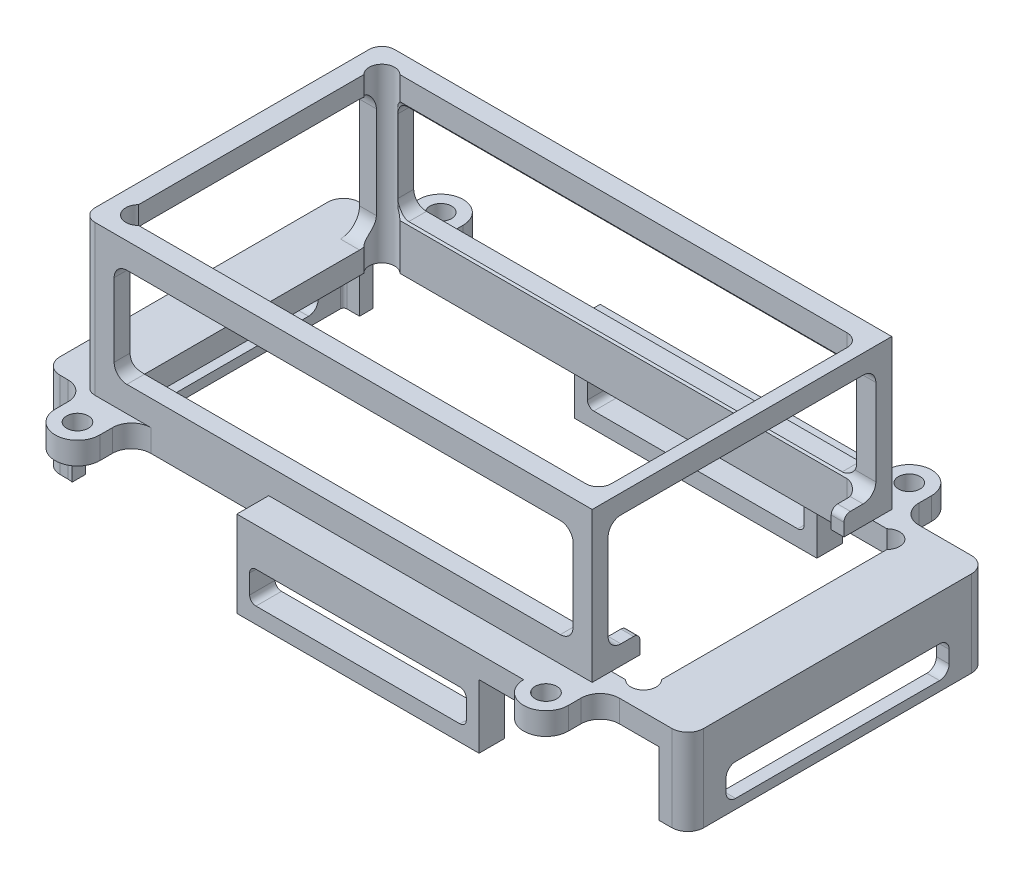
from build123d import *

# Parameters (mm, degrees)
EXTRUDE_1_DEPTH     = 23.5
SKETCH_2_R          = 1.7
EXTRUDE_2_DEPTH     = 3.5
FILLET_1_R          = 2.5
EXTRUDE_1_2_DEPTH   = 10
CUT_EXTRUDE_1_REACH = 97
CUT_EXTRUDE_2_DEPTH = 47
CUT_EXTRUDE_3_REACH = 88
CUT_EXTRUDE_4_DEPTH = 3.5
CUT_EXTRUDE_5_REACH = 4
SKETCH_9_W          = 45
SKETCH_9_H          = 3.5
EXTRUDE_3_DEPTH     = 5
SKETCH_10_W         = 45
SKETCH_10_H         = 3.5
EXTRUDE_4_DEPTH     = 5
SKETCH_11_W         = 38
SKETCH_11_H         = 4
EXTRUDE_5_DEPTH     = 10
CUT_EXTRUDE_6_DEPTH = 57
FILLET_3_R          = 3


with BuildPart() as part:
    # 草图1 → Extrude 1 (new body)
    with BuildSketch(Plane(origin=(0, 0, 0), x_dir=(1, 0, 0), z_dir=(0, 1, 0))):
        with BuildLine():
            Line((-38, 23.5), (40, 23.5))
            Line((40, 23.5), (40, -23.5))
            Line((40, -23.5), (-38, -23.5))
            ThreePointArc((-38, -23.5), (-39.414213562, -22.914213562), (-40, -21.5))
            Line((-40, -21.5), (-40, 21.5))
            ThreePointArc((-40, 21.5), (-39.414213562, 22.914213562), (-38, 23.5))
        make_face()
        with BuildLine():
            Line((-34.171572875, -20.5), (36, -20.5))
            ThreePointArc((36, -20.5), (37.414213562, -19.914213562), (38, -18.5))
            Line((38, -18.5), (38, 18.5))
            ThreePointArc((38, 18.5), (37.414213562, 19.914213562), (36, 20.5))
            Line((36, 20.5), (-34.171572875, 20.5))
            ThreePointArc((-34.171572875, 20.5), (-37, 20.5), (-37, 17.671572875))
            Line((-37, 17.671572875), (-37, -17.671572875))
            ThreePointArc((-37, -17.671572875), (-37, -20.5), (-34.171572875, -20.5))
        make_face(mode=Mode.SUBTRACT)
    extrude(amount=EXTRUDE_1_DEPTH)

    # 草图2 → 凸台-拉伸2 (add)
    with BuildSketch(Plane.XZ):
        with BuildLine():
            Line((55, 0), (55, 23.5))
            Line((55, 23.5), (41.25, 23.5))
            Line((41.25, 23.5), (41.25, 28.5))
            ThreePointArc((41.25, 28.5), (37.75, 32), (34.25, 28.5))
            Line((34.25, 28.5), (34.25, 23.5))
            Line((34.25, 23.5), (-32.25, 23.5))
            Line((-32.25, 23.5), (-32.25, 28.5))
            ThreePointArc((-32.25, 28.5), (-35.75, 32), (-39.25, 28.5))
            Line((-39.25, 28.5), (-39.25, 23.5))
            Line((-39.25, 23.5), (-46, 23.5))
            Line((-46, 23.5), (-46, -23.5))
            Line((-46, -23.5), (-39.25, -23.5))
            Line((-39.25, -23.5), (-39.25, -28.5))
            ThreePointArc((-39.25, -28.5), (-35.75, -32), (-32.25, -28.5))
            Line((-32.25, -28.5), (-32.25, -23.5))
            Line((-32.25, -23.5), (34.25, -23.5))
            Line((34.25, -23.5), (34.25, -28.5))
            ThreePointArc((34.25, -28.5), (37.75, -32), (41.25, -28.5))
            Line((41.25, -28.5), (41.25, -23.5))
            Line((41.25, -23.5), (55, -23.5))
            Line((55, -23.5), (55, 0))
        make_face()
        with Locations((37.75, 28.5)):
            Circle(SKETCH_2_R, mode=Mode.SUBTRACT)
        with Locations((37.75, -28.5)):
            Circle(SKETCH_2_R, mode=Mode.SUBTRACT)
        with Locations((-35.75, -28.5)):
            Circle(SKETCH_2_R, mode=Mode.SUBTRACT)
        with Locations((-35.75, 28.5)):
            Circle(SKETCH_2_R, mode=Mode.SUBTRACT)
        with BuildLine():
            Line((-34.171572875, 20.5), (42.231907087, 20.5))
            ThreePointArc((42.231907087, 20.5), (45.060334211, 20.5), (45.060334211, 17.671572875))
            Line((45.060334211, 17.671572875), (45.060334211, -17.671572875))
            ThreePointArc((45.060334211, -17.671572875), (45.060334211, -20.5), (42.231907087, -20.5))
            Line((42.231907087, -20.5), (-34.171572875, -20.5))
            ThreePointArc((-34.171572875, -20.5), (-37, -20.5), (-37, -17.671572875))
            Line((-37, -17.671572875), (-37, 17.671572875))
            ThreePointArc((-37, 17.671572875), (-37, 20.5), (-34.171572875, 20.5))
        make_face(mode=Mode.SUBTRACT)
    extrude(amount=EXTRUDE_2_DEPTH)

    # 圆角1
    fillet_1_edges = [part.edges().sort_by_distance(p)[0] for p in [
        (55, -1.75, -23.5),
        (55, -1.75, 23.5),
        (-46, -1.75, 23.5),
        (-46, -1.75, -23.5),
    ]]
    fillet(fillet_1_edges, radius=FILLET_1_R)

    # 草图3 → Extrude 1 2 (add)
    with BuildSketch(Plane.XZ.offset(3.5)):
        with BuildLine():
            Line((50.5, -23.5), (52.5, -23.5))
            ThreePointArc((52.5, -23.5), (54.267766953, -22.767766953), (55, -21))
            Line((55, -21), (55, 21))
            ThreePointArc((55, 21), (54.267766953, 22.767766953), (52.5, 23.5))
            Line((52.5, 23.5), (50.5, 23.5))
            Line((50.5, 23.5), (50.5, 21.5))
            Line((50.5, 21.5), (52.5, 21.5))
            ThreePointArc((52.5, 21.5), (52.853553391, 21.353553391), (53, 21))
            Line((53, 21), (53, -21))
            ThreePointArc((53, -21), (52.853553391, -21.353553391), (52.5, -21.5))
            Line((52.5, -21.5), (50.5, -21.5))
            Line((50.5, -21.5), (50.5, -23.5))
        make_face()
        with BuildLine():
            Line((-41.5, 23.5), (-43.5, 23.5))
            ThreePointArc((-43.5, 23.5), (-45.267766953, 22.767766953), (-46, 21))
            Line((-46, 21), (-46, -21))
            ThreePointArc((-46, -21), (-45.267766953, -22.767766953), (-43.5, -23.5))
            Line((-43.5, -23.5), (-41.5, -23.5))
            Line((-41.5, -23.5), (-41.5, -21.5))
            Line((-41.5, -21.5), (-43.5, -21.5))
            ThreePointArc((-43.5, -21.5), (-43.853553391, -21.353553391), (-44, -21))
            Line((-44, -21), (-44, 21))
            ThreePointArc((-44, 21), (-43.853553391, 21.353553391), (-43.5, 21.5))
            Line((-43.5, 21.5), (-41.5, 21.5))
            Line((-41.5, 21.5), (-41.5, 23.5))
        make_face()
    extrude(amount=EXTRUDE_1_2_DEPTH)

    # 草图4 → 切除-拉伸1 (cut, up to next)
    with BuildSketch(Plane.ZY.offset(40), mode=Mode.PRIVATE) as cut_extrude_1_sk1:
        with BuildLine():
            Line((17, 0), (-17, 0))
            ThreePointArc((-17, 0), (-19.121320344, 0.878679656), (-20, 3))
            Line((-20, 3), (-20, 17.5))
            ThreePointArc((-20, 17.5), (-19.121320344, 19.621320344), (-17, 20.5))
            Line((-17, 20.5), (17, 20.5))
            ThreePointArc((17, 20.5), (19.121320344, 19.621320344), (20, 17.5))
            Line((20, 17.5), (20, 3))
            ThreePointArc((20, 3), (19.121320344, 0.878679656), (17, 0))
        make_face()
    cut_extrude_1_tool1 = extrude(cut_extrude_1_sk1.sketch, amount=-CUT_EXTRUDE_1_REACH, mode=Mode.PRIVATE) & part.part
    add(cut_extrude_1_tool1.solids().sort_by_distance((-40, 10.25, 0))[0], mode=Mode.SUBTRACT)

    # 草图5 → 切除-拉伸2 (cut)
    with BuildSketch(Plane(origin=(0, 0, -23.5), x_dir=(-1, 0, 0), z_dir=(0, 0, -1))):
        with BuildLine():
            Line((-37, 11.75), (-37, 17.5))
            ThreePointArc((-37, 17.5), (-36.414213562, 18.914213562), (-35, 19.5))
            Line((-35, 19.5), (33, 19.5))
            ThreePointArc((33, 19.5), (34.414213562, 18.914213562), (35, 17.5))
            Line((35, 17.5), (35, 6))
            ThreePointArc((35, 6), (34.414213562, 4.585786438), (33, 4))
            Line((33, 4), (-35, 4))
            ThreePointArc((-35, 4), (-36.414213562, 4.585786438), (-37, 6))
            Line((-37, 6), (-37, 11.75))
        make_face()
    extrude(amount=-CUT_EXTRUDE_2_DEPTH, mode=Mode.SUBTRACT)

    # 草图6 → 切除-拉伸3 (cut, up to next)
    with BuildSketch(Plane(origin=(40, 0, 0), x_dir=(0, 0, -1), z_dir=(1, 0, 0)), mode=Mode.PRIVATE) as cut_extrude_3_sk1:
        with BuildLine():
            Line((21, 5), (21, 18.5))
            ThreePointArc((21, 18.5), (20.414213562, 19.914213562), (19, 20.5))
            Line((19, 20.5), (-19, 20.5))
            ThreePointArc((-19, 20.5), (-20.414213562, 19.914213562), (-21, 18.5))
            Line((-21, 18.5), (-21, 5))
            ThreePointArc((-21, 5), (-20.414213562, 3.585786438), (-19, 3))
            Line((-19, 3), (-17, 3))
            ThreePointArc((-17, 3), (-16.292893219, 2.707106781), (-16, 2))
            Line((-16, 2), (-16, 0))
            Line((-16, 0), (16, 0))
            Line((16, 0), (16, 2))
            ThreePointArc((16, 2), (16.292893219, 2.707106781), (17, 3))
            Line((17, 3), (19, 3))
            ThreePointArc((19, 3), (20.414213562, 3.585786438), (21, 5))
        make_face()
    cut_extrude_3_tool1 = extrude(cut_extrude_3_sk1.sketch, amount=-CUT_EXTRUDE_3_REACH, mode=Mode.PRIVATE) & part.part
    add(cut_extrude_3_tool1.solids().sort_by_distance((40, 10.556936, 0))[0], mode=Mode.SUBTRACT)

    # 草图7 → 切除-拉伸4 (cut)
    with BuildSketch(Plane.ZY.offset(-53)):
        with BuildLine():
            Line((16, -12), (-16, -12))
            ThreePointArc((-16, -12), (-17.060660172, -11.560660172), (-17.5, -10.5))
            Line((-17.5, -10.5), (-17.5, -8.5))
            ThreePointArc((-17.5, -8.5), (-17.060660172, -7.439339828), (-16, -7))
            Line((-16, -7), (16, -7))
            ThreePointArc((16, -7), (17.060660172, -7.439339828), (17.5, -8.5))
            Line((17.5, -8.5), (17.5, -10.5))
            ThreePointArc((17.5, -10.5), (17.060660172, -11.560660172), (16, -12))
        make_face()
    extrude(amount=-CUT_EXTRUDE_4_DEPTH, mode=Mode.SUBTRACT)

    # 草图8 → 切除-拉伸5 (cut, up to next)
    with BuildSketch(Plane(origin=(-44, 0, 0), x_dir=(0, 0, -1), z_dir=(1, 0, 0)), mode=Mode.PRIVATE) as cut_extrude_5_sk1:
        with BuildLine():
            Line((16, -12), (-16, -12))
            ThreePointArc((-16, -12), (-17.060660172, -11.560660172), (-17.5, -10.5))
            Line((-17.5, -10.5), (-17.5, -8.5))
            ThreePointArc((-17.5, -8.5), (-17.060660172, -7.439339828), (-16, -7))
            Line((-16, -7), (16, -7))
            ThreePointArc((16, -7), (17.060660172, -7.439339828), (17.5, -8.5))
            Line((17.5, -8.5), (17.5, -10.5))
            ThreePointArc((17.5, -10.5), (17.060660172, -11.560660172), (16, -12))
        make_face()
    cut_extrude_5_tool1 = extrude(cut_extrude_5_sk1.sketch, amount=-CUT_EXTRUDE_5_REACH, mode=Mode.PRIVATE) & part.part
    add(cut_extrude_5_tool1.solids().sort_by_distance((-44, -9.5, 0))[0], mode=Mode.SUBTRACT)

    # 草图9 → 凸台-拉伸3 (add)
    with BuildSketch(Plane.XY.offset(23.5)):
        with Locations((11.75, -1.75)):
            Rectangle(SKETCH_9_W, SKETCH_9_H)
    extrude(amount=EXTRUDE_3_DEPTH)

    # 草图10 → 凸台-拉伸4 (add)
    with BuildSketch(Plane(origin=(0, 0, -23.5), x_dir=(-1, 0, 0), z_dir=(0, 0, -1))):
        with Locations((-11.75, -1.75)):
            Rectangle(SKETCH_10_W, SKETCH_10_H)
    extrude(amount=EXTRUDE_4_DEPTH)

    # 草图11 → 凸台-拉伸5 (add)
    with BuildSketch(Plane.XZ.offset(3.5)):
        with Locations((8.25, -26.5)):
            Rectangle(SKETCH_11_W, SKETCH_11_H)
        with Locations((8.25, 26.5)):
            Rectangle(SKETCH_11_W, SKETCH_11_H)
    extrude(amount=EXTRUDE_5_DEPTH)

    # 草图12 → 切除-拉伸6 (cut)
    with BuildSketch(Plane.XY.offset(28.5)):
        with BuildLine():
            Line((24.25, -11), (-7.75, -11))
            ThreePointArc((-7.75, -11), (-8.457106781, -10.707106781), (-8.75, -10))
            Line((-8.75, -10), (-8.75, -7))
            ThreePointArc((-8.75, -7), (-8.457106781, -6.292893219), (-7.75, -6))
            Line((-7.75, -6), (24.25, -6))
            ThreePointArc((24.25, -6), (24.957106781, -6.292893219), (25.25, -7))
            Line((25.25, -7), (25.25, -10))
            ThreePointArc((25.25, -10), (24.957106781, -10.707106781), (24.25, -11))
        make_face()
    extrude(amount=-CUT_EXTRUDE_6_DEPTH, mode=Mode.SUBTRACT)

    # 圆角3
    fillet_3_edges = [part.edges().sort_by_distance(p)[0] for p in [
        (-39.25, -1.75, 23.5),
        (-32.25, -1.75, 23.5),
        (41.25, -1.75, 23.5),
        (41.25, -1.75, -23.5),
        (-39.25, -1.75, -23.5),
        (-32.25, -1.75, -23.5),
    ]]
    fillet(fillet_3_edges, radius=FILLET_3_R)


solid = part.part
